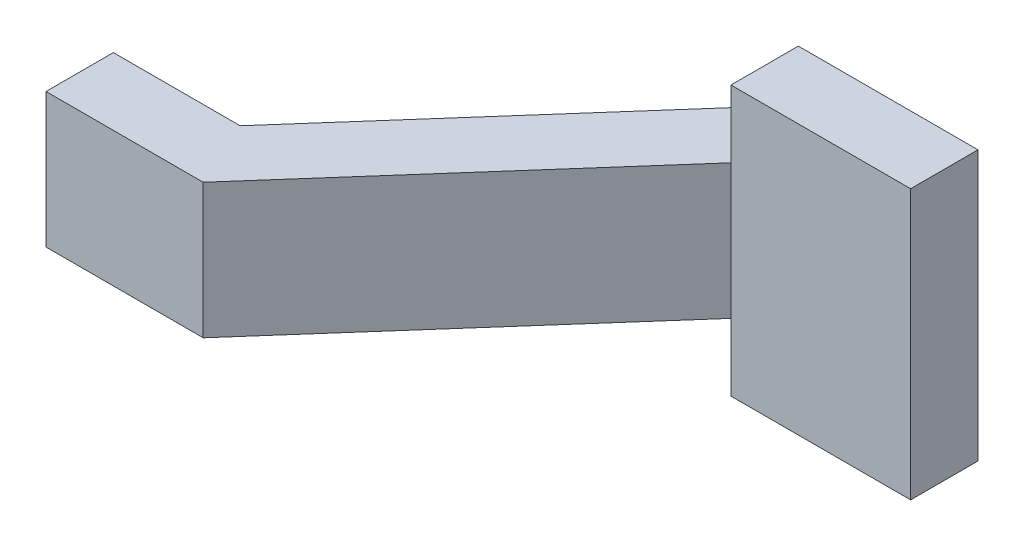
from build123d import *

# Parameters (mm, degrees)
BOSS_EXTRUDE1_DEPTH = 0.762
SKETCH2_W           = 2.286
SKETCH2_H           = 0.381
CUT_EXTRUDE1_DEPTH  = 2.9685


with BuildPart() as part:
    # Sketch1 → Boss-Extrude1 (new body, symmetric)
    with BuildSketch(Plane(origin=(0, 0, 0), x_dir=(1, 0, 0), z_dir=(0, 1, 0))):
        Polygon((0, 0), (0.889, 0), (2.286, 1.5875), (3.302, 1.5875), (3.302, 1.9685), (2.113762829, 1.9685), (0.716762829, 0.381), (0, 0.381), align=None)
    extrude(amount=BOSS_EXTRUDE1_DEPTH, both=True)

    # Sketch2 → Cut-Extrude1 (cut, through all)
    with BuildSketch(Plane(origin=(0, 0, -1.9685), x_dir=(-1, 0, 0), z_dir=(0, 0, -1))):
        with Locations((-1.143, 0.5715)):
            Rectangle(SKETCH2_W, SKETCH2_H)
    cut_extrude1 = extrude(amount=-CUT_EXTRUDE1_DEPTH, mode=Mode.SUBTRACT)

    # Mirror1: Cut-Extrude1 across plane
    add(cut_extrude1.mirror(Plane.ZX), mode=Mode.SUBTRACT)


solid = part.part
